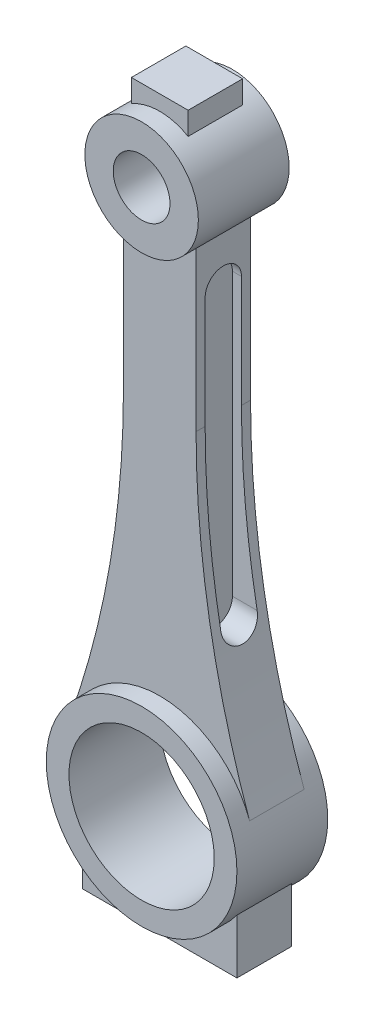
from build123d import *

# Parameters (mm, degrees)
SKETCH1_R             = 12.5
SKETCH1_R_2           = 6.25
BOSS_EXTRUDE1_DEPTH   = 10
SKETCH1_R_3           = 21
SKETCH1_R_4           = 16
BOSS_EXTRUDE1_2_DEPTH = 10
BOSS_EXTRUDE2_DEPTH   = 6
CUT_EXTRUDE1_START    = 6
CUT_EXTRUDE1_DEPTH    = 132.802456026


with BuildPart() as part:
    # Sketch1 → Boss-Extrude1 (new, symmetric)
    with BuildSketch(Plane.XY):
        with Locations((0, 120)):
            Circle(SKETCH1_R)
        with Locations((0, 120)):
            Circle(SKETCH1_R_2, mode=Mode.SUBTRACT)
    extrude(amount=BOSS_EXTRUDE1_DEPTH, both=True)



with BuildPart() as body_2:
    # Sketch1 → Boss-Extrude1 2 (new, symmetric)
    with BuildSketch(Plane.XY):
        Circle(SKETCH1_R_3)
        Circle(SKETCH1_R_4, mode=Mode.SUBTRACT)
    extrude(amount=BOSS_EXTRUDE1_2_DEPTH, both=True)


with BuildPart() as part_1:
    add(part.part)

    add(body_2.part)  # Boss-Extrude2 merges body 2
    # Sketch1_3 → Boss-Extrude2 (add, symmetric)
    with BuildSketch(Plane.XY):
        with BuildLine():
            ThreePointArc((8, 110.395313644), (0, 107.5), (-8, 110.395313644))
            Line((-8, 110.395313644), (-8, 75.395313644))
            ThreePointArc((-8, 75.395313644), (-10.96842855, 40.709642053), (-19.787382488, 7.032744434))
            ThreePointArc((-19.787382488, 7.032744434), (0, 21), (19.787382488, 7.032744434))
            ThreePointArc((19.787382488, 7.032744434), (10.96842855, 40.709642053), (8, 75.395313644))
            Line((8, 75.395313644), (8, 110.395313644))
        make_face()
        with BuildLine():
            Line((-6.25, 135.825317547), (-6.25, 130.825317547))
            ThreePointArc((-6.25, 130.825317547), (0, 132.5), (6.25, 130.825317547))
            Line((6.25, 130.825317547), (6.25, 135.825317547))
            Line((6.25, 135.825317547), (-6.25, 135.825317547))
        make_face()
        with BuildLine():
            ThreePointArc((17, -12.328828006), (0, -21), (-17, -12.328828006))
            Line((-17, -12.328828006), (-17, -24.328828006))
            Line((-17, -24.328828006), (17, -24.328828006))
            Line((17, -24.328828006), (17, -12.328828006))
        make_face()
    extrude(amount=BOSS_EXTRUDE2_DEPTH, both=True)

    # Sketch2 → Cut-Extrude1 (cut, through all)
    with BuildSketch(Plane(origin=(0, 0, 0), x_dir=(0, 0, -1), z_dir=(1, 0, 0)).offset(CUT_EXTRUDE1_START)):
        with BuildLine():
            Line((4, 38), (4, 100))
            ThreePointArc((4, 100), (0, 104), (-4, 100))
            Line((-4, 100), (-4, 38))
            ThreePointArc((-4, 38), (0, 34), (4, 38))
        make_face()
    cut_extrude1 = extrude(amount=CUT_EXTRUDE1_DEPTH, mode=Mode.SUBTRACT)

    # Mirror1: Cut-Extrude1 across plane
    add(cut_extrude1.mirror(Plane(origin=(0, 0, 0), x_dir=(0, 0, 1), z_dir=(1, 0, 0))), mode=Mode.SUBTRACT)


solid = part_1.part
